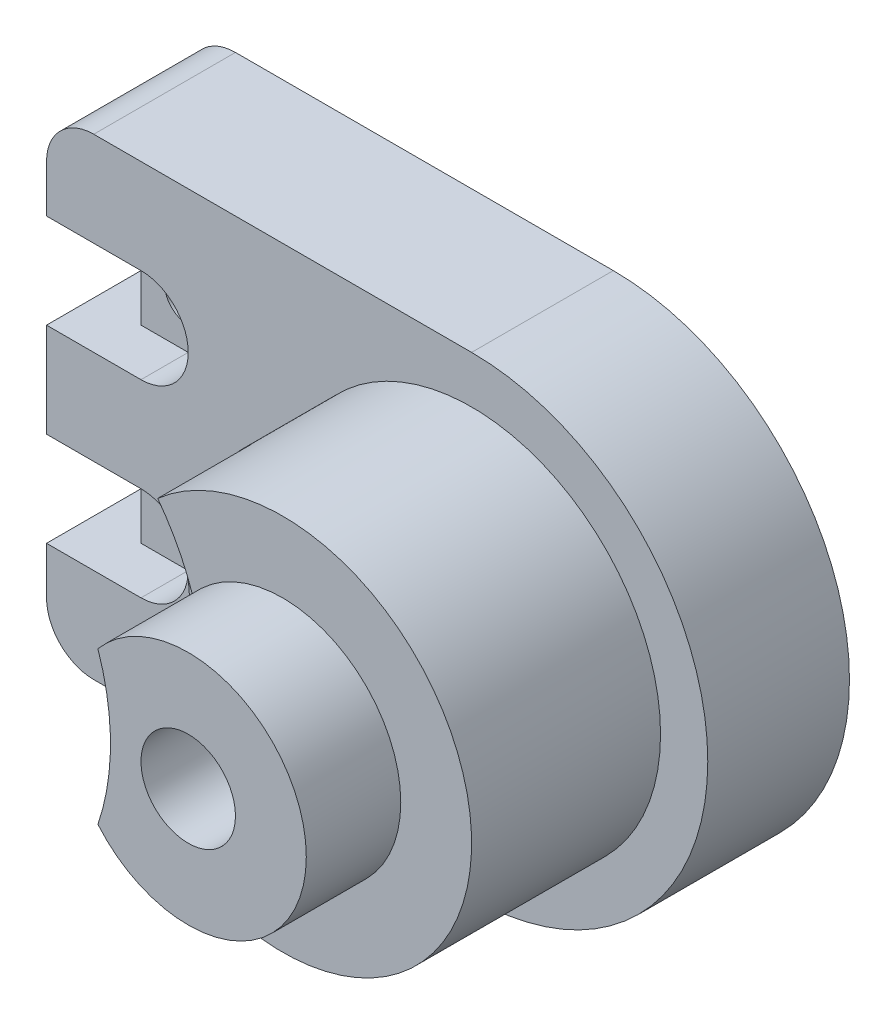
from build123d import *

# Parameters (mm, degrees)
BOSS_EXTRUDE1_DEPTH        = 30
SKETCH2_W                  = 10
SKETCH2_H                  = 20
CUT_EXTRUDE1_DEPTH         = 30
SKETCH3_R                  = 40
BOSS_EXTRUDE2_DEPTH        = 40
SKETCH4_R                  = 25
BOSS_EXTRUDE3_DEPTH        = 20
CUT_EXTRUDE2_DEPTH         = 42
CUT_EXTRUDE3_DEPTH         = 42
BOSS_EXTRUDE4_START        = 10
BOSS_EXTRUDE4_DEPTH        = 10
BOSS_EXTRUDE5_START        = 10
BOSS_EXTRUDE5_DEPTH        = 10
SKETCH9_R                  = 5
CUT_EXTRUDE4_DEPTH         = 10
CUT_EXTRUDE5_DEPTH         = 20
CUT_EXTRUDE5_DEPTH_BACK    = 20
SKETCH11_R                 = 5
CUT_EXTRUDE6_DEPTH         = 50
F_20_0MM_DOWEL_HOLE1_D     = 20
F_20_0MM_DOWEL_HOLE1_DEPTH = 30
F_20_0MM_DOWEL_HOLE1_TIP   = 6.00860619


with BuildPart() as part:
    # Sketch1 → Boss-Extrude1 (new body)
    with BuildSketch(Plane.XY):
        with BuildLine():
            Line((0, 100), (0, 0))
            Line((0, 0), (90, 0))
            ThreePointArc((90, 0), (140, 50), (90, 100))
            Line((90, 100), (0, 100))
        make_face()
    extrude(amount=BOSS_EXTRUDE1_DEPTH)

    # Sketch2 → Cut-Extrude1 (cut)
    with BuildSketch(Plane.XY.offset(30)):
        with BuildLine():
            Line((0, 90), (0, 100))
            Line((0, 100), (10, 100))
            ThreePointArc((10, 100), (2.928932188, 97.071067812), (0, 90))
        make_face()
        with BuildLine():
            Line((0, 10), (0, 0))
            Line((0, 0), (10, 0))
            ThreePointArc((10, 0), (2.928932188, 2.928932188), (0, 10))
        make_face()
        with Locations((5, 70)):
            Rectangle(SKETCH2_W, SKETCH2_H)
        with Locations((5, 30)):
            Rectangle(SKETCH2_W, SKETCH2_H)
    extrude(amount=-CUT_EXTRUDE1_DEPTH, mode=Mode.SUBTRACT)

    # Sketch3 → Boss-Extrude2 (add)
    with BuildSketch(Plane.XY.offset(30)):
        with Locations((90, 50)):
            Circle(SKETCH3_R)
    extrude(amount=BOSS_EXTRUDE2_DEPTH)

    # Sketch4 → Boss-Extrude3 (add)
    with BuildSketch(Plane.XY.offset(70)):
        with Locations((90, 50)):
            Circle(SKETCH4_R)
    extrude(amount=BOSS_EXTRUDE3_DEPTH)

    # Sketch5 → Cut-Extrude2 (cut)
    with BuildSketch(Plane.XY.offset(30)):
        with BuildLine():
            Line((20, 80), (10, 80))
            Line((10, 80), (10, 60))
            Line((10, 60), (20, 60))
            ThreePointArc((20, 60), (30, 70), (20, 80))
        make_face()
    extrude(amount=-CUT_EXTRUDE2_DEPTH, mode=Mode.SUBTRACT)

    # Sketch6 → Cut-Extrude3 (cut)
    with BuildSketch(Plane.XY.offset(30)):
        with BuildLine():
            Line((20, 40), (10, 40))
            Line((10, 40), (10, 20))
            Line((10, 20), (20, 20))
            ThreePointArc((20, 20), (30, 30), (20, 40))
        make_face()
    extrude(amount=-CUT_EXTRUDE3_DEPTH, mode=Mode.SUBTRACT)

    # Sketch7 → Boss-Extrude4 (add)
    with BuildSketch(Plane.XY.offset(10).offset(BOSS_EXTRUDE4_START)):
        with BuildLine():
            Line((10, 80), (10, 60))
            Line((10, 60), (20, 60))
            ThreePointArc((20, 60), (30, 70), (20, 80))
            Line((20, 80), (10, 80))
        make_face()
    extrude(amount=-BOSS_EXTRUDE4_DEPTH)

    # Sketch8 → Boss-Extrude5 (add)
    with BuildSketch(Plane.XY.offset(10).offset(BOSS_EXTRUDE5_START)):
        with BuildLine():
            Line((10, 40), (10, 20))
            Line((10, 20), (20, 20))
            ThreePointArc((20, 20), (30, 30), (20, 40))
            Line((20, 40), (10, 40))
        make_face()
    extrude(amount=-BOSS_EXTRUDE5_DEPTH)

    # Sketch9 → Cut-Extrude4 (cut)
    with BuildSketch(Plane.XY.offset(20)):
        with Locations((20, 70)):
            Circle(SKETCH9_R)
        with Locations((20, 30)):
            Circle(SKETCH9_R)
    extrude(amount=-CUT_EXTRUDE4_DEPTH, mode=Mode.SUBTRACT)

    # Sketch10 → Cut-Extrude5 (cut, two sides: drawn at the far end of the back side and taken through both)
    with BuildSketch(Plane.XY.offset(70).offset(-CUT_EXTRUDE5_DEPTH_BACK)):
        with BuildLine():
            ThreePointArc((63.542486889, 80), (50, 50), (63.542486889, 20))
            ThreePointArc((63.542486889, 20), (73.542486889, 50), (63.542486889, 80))
        make_face()
    extrude(amount=CUT_EXTRUDE5_DEPTH + CUT_EXTRUDE5_DEPTH_BACK, mode=Mode.SUBTRACT)

    # Sketch11 → Cut-Extrude6 (cut)
    with BuildSketch(Plane.XY.offset(50)):
        with Locations((60, 50)):
            Circle(SKETCH11_R)
    extrude(amount=-CUT_EXTRUDE6_DEPTH, mode=Mode.SUBTRACT)

    # Ø20.0mm Dowel Hole1
    with Locations(Plane(origin=(90, 50, 90), x_dir=(1, 0, 0), z_dir=(0, 0, 1))):
        with Locations((0, 0)):
            Hole(F_20_0MM_DOWEL_HOLE1_D / 2, depth=F_20_0MM_DOWEL_HOLE1_DEPTH)
            with Locations((0, 0, -(F_20_0MM_DOWEL_HOLE1_DEPTH + F_20_0MM_DOWEL_HOLE1_TIP / 2))):  # 118° drill point
                Cone(0, F_20_0MM_DOWEL_HOLE1_D / 2, F_20_0MM_DOWEL_HOLE1_TIP, mode=Mode.SUBTRACT)


solid = part.part
